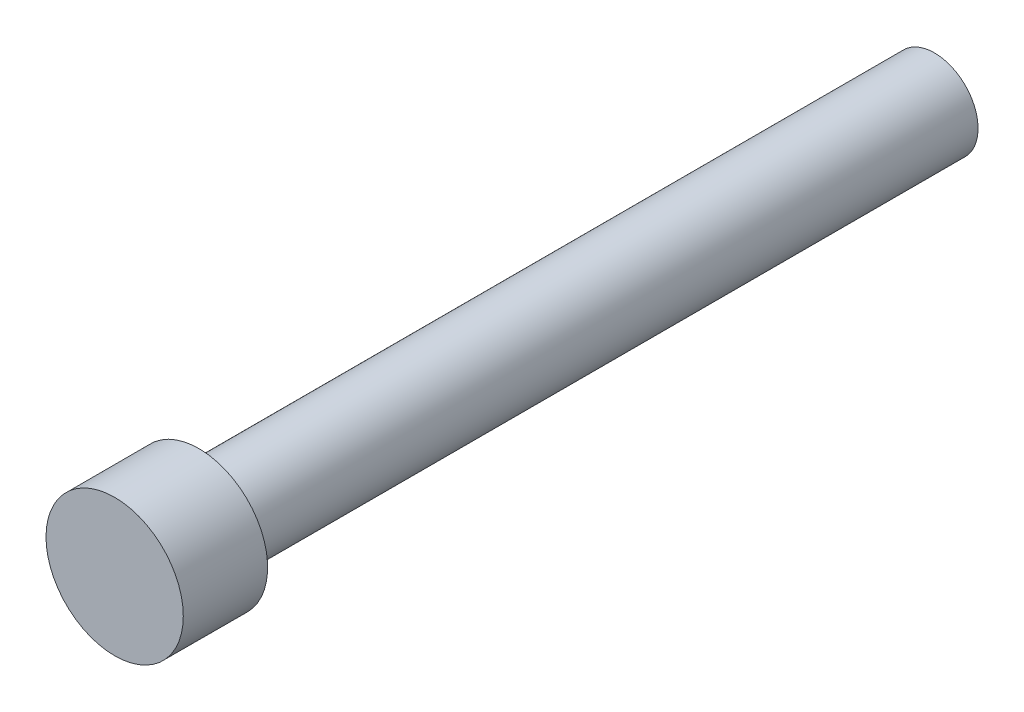
from build123d import *

# Parameters (mm, degrees)
SKETCH1_R         = 1.778
EXTRUDE1_DEPTH    = 21.2344
SKETCH3_OUTSIDE_W = 9.92
SKETCH3_OUTSIDE_H = 9.92
SKETCH3_OUTSIDE_R = 1.1303
EXTRUDE2_DEPTH    = 19.05


with BuildPart() as part:
    # Sketch1 → Extrude1 (new body)
    with BuildSketch(Plane.XY):
        Circle(SKETCH1_R)
    extrude(amount=EXTRUDE1_DEPTH)

    # Sketch3 outside → Extrude2 (cut)
    with BuildSketch(Plane(origin=(0, 0, 0), x_dir=(-1, 0, 0), z_dir=(0, 0, -1))):
        Rectangle(SKETCH3_OUTSIDE_W, SKETCH3_OUTSIDE_H)
        Circle(SKETCH3_OUTSIDE_R, mode=Mode.SUBTRACT)
    extrude(amount=-EXTRUDE2_DEPTH, mode=Mode.SUBTRACT)


solid = part.part
